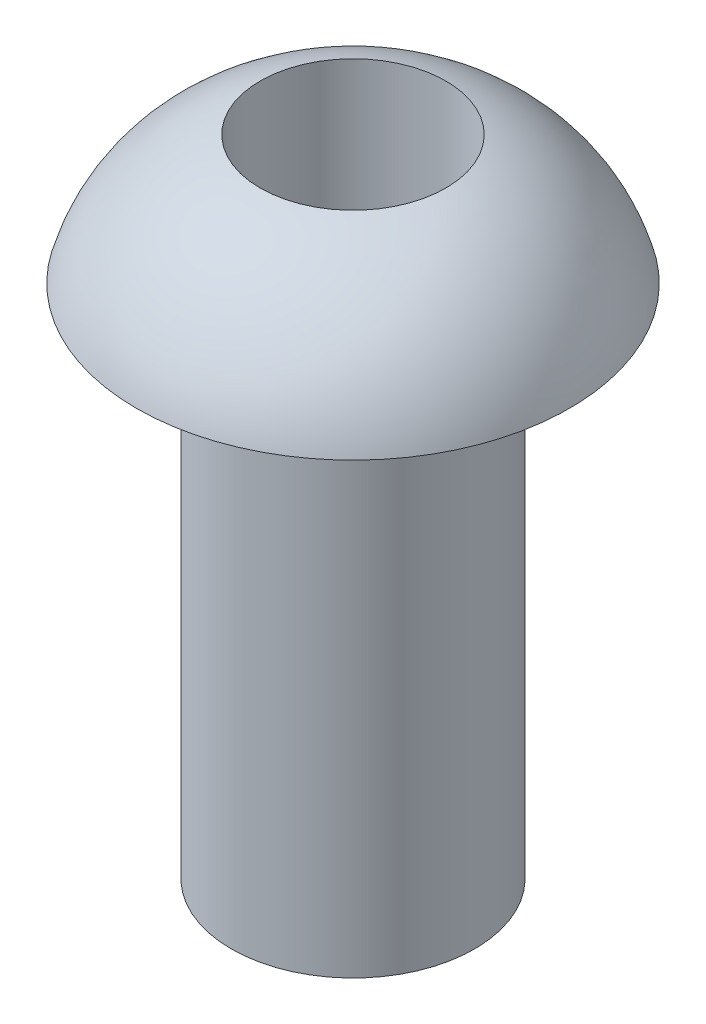
from build123d import *

# Parameters (mm, degrees)
SKETCH1_R           = 0.7493
SKETCH1_R_2         = 0.5715
BARREL_DEPTH        = 3.175
SKETCH2_R           = 1.3335
SKETCH2_R_2         = 0.5715
BOSS_EXTRUDE2_DEPTH = 0.79375


with BuildPart() as part:
    # Sketch1 → Barrel (new body)
    with BuildSketch(Plane(origin=(0, 0, 0), x_dir=(1, 0, 0), z_dir=(0, 1, 0))):
        Circle(SKETCH1_R)
        Circle(SKETCH1_R_2, mode=Mode.SUBTRACT)
    extrude(amount=BARREL_DEPTH)

    # Sketch2 → Boss-Extrude2 (add)
    with BuildSketch(Plane(origin=(0, 3.175, 0), x_dir=(1, 0, 0), z_dir=(0, 1, 0))):
        Circle(SKETCH2_R)
        Circle(SKETCH2_R_2, mode=Mode.SUBTRACT)
    extrude(amount=BOSS_EXTRUDE2_DEPTH)

    # Sketch4 → Cut-Revolve11 (revolve, cut)
    with BuildSketch(Plane(origin=(0, 0, 0), x_dir=(0, 0, -1), z_dir=(1, 0, 0))):
        with BuildLine():
            Line((-1.3335, 3.175), (-1.3335, 3.96875))
            Line((-1.3335, 3.96875), (-0.5715, 3.96875))
            ThreePointArc((-0.5715, 3.96875), (-1.054623655, 3.669913708), (-1.3335, 3.175))
        make_face()
    revolve(axis=Axis((0, 3.96875, 0), (0, -1, 0)), mode=Mode.SUBTRACT)


solid = part.part
